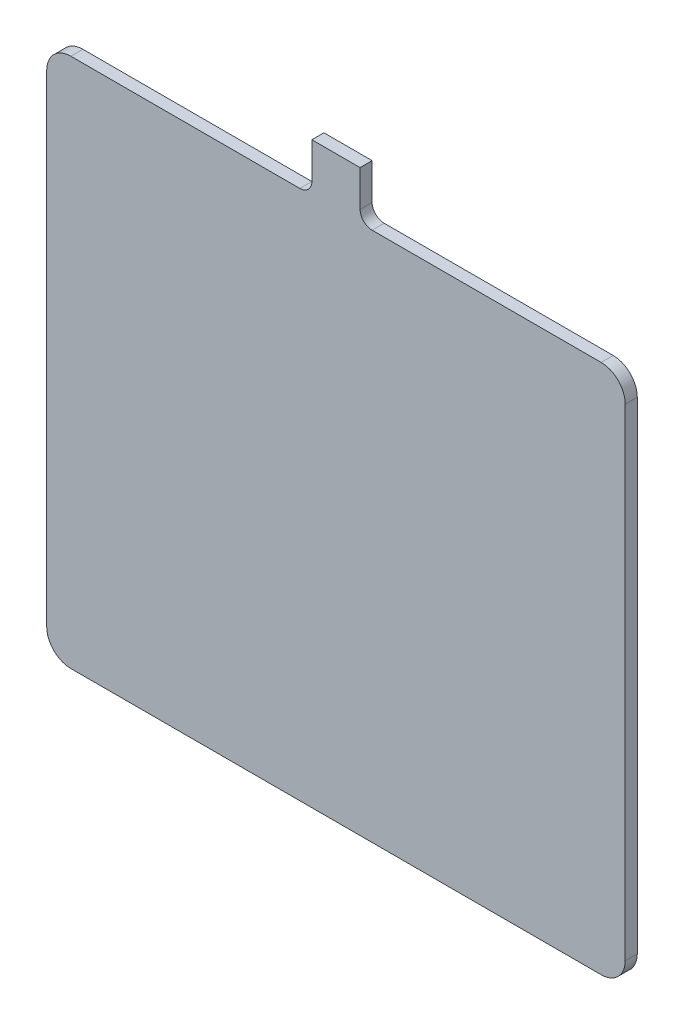
from build123d import *

# Parameters (mm, degrees)
BOSS_EXTRU_1_DEPTH = 10


with BuildPart() as part:
    # Esquisse1 → Boss.-Extru.1 (new body)
    with BuildSketch(Plane.XY):
        with BuildLine():
            Line((-220, 295), (-30, 295))
            ThreePointArc((-30, 295), (-22.928932188, 297.928932188), (-20, 305))
            Line((-20, 305), (-20, 335))
            Line((-20, 335), (20, 335))
            Line((20, 335), (20, 305))
            ThreePointArc((20, 305), (22.928932188, 297.928932188), (30, 295))
            Line((30, 295), (220, 295))
            ThreePointArc((220, 295), (234.142135624, 289.142135624), (240, 275))
            Line((240, 275), (240, -125))
            ThreePointArc((240, -125), (234.142135624, -139.142135624), (220, -145))
            Line((220, -145), (-220, -145))
            ThreePointArc((-220, -145), (-234.142135624, -139.142135624), (-240, -125))
            Line((-240, -125), (-240, 275))
            ThreePointArc((-240, 275), (-234.142135624, 289.142135624), (-220, 295))
        make_face()
    extrude(amount=BOSS_EXTRU_1_DEPTH)


solid = part.part
